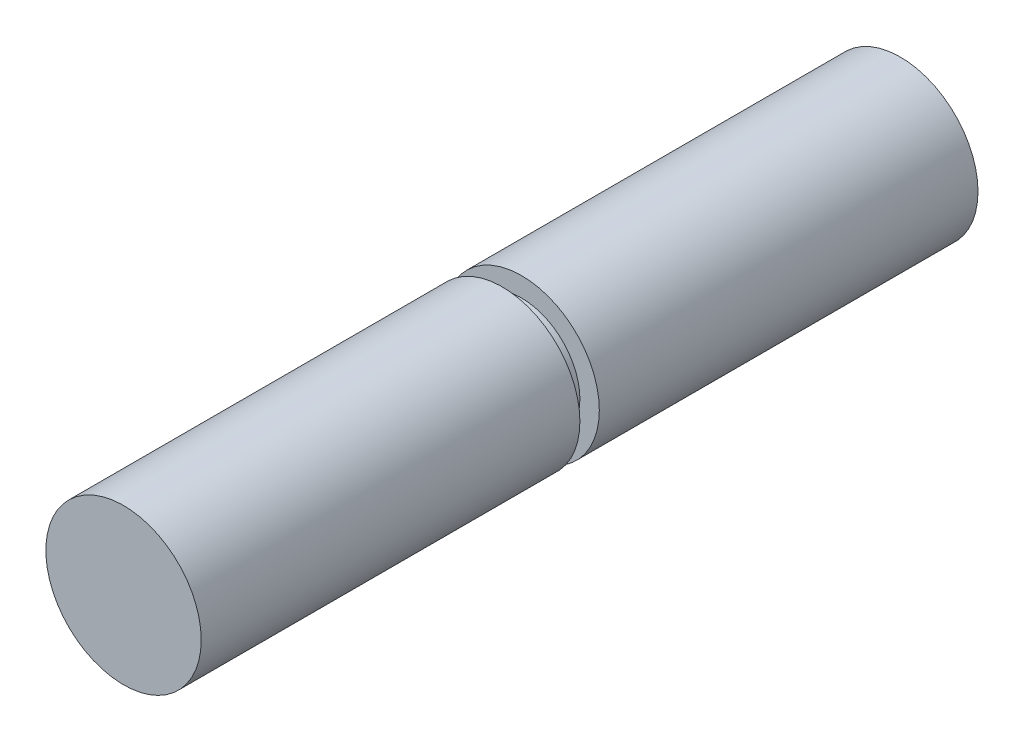
from build123d import *

# Parameters (mm, degrees)
SKETCH1_R           = 25.4
BOSS_EXTRUDE1_DEPTH = 127
SKETCH2_W           = 6.35
SKETCH2_H           = 6.35


with BuildPart() as part:
    # Sketch1 → Boss-Extrude1 (new body, symmetric)
    with BuildSketch(Plane.XY):
        Circle(SKETCH1_R)
    extrude(amount=BOSS_EXTRUDE1_DEPTH, both=True)

    # Sketch2 → Cut-Revolve1 (revolve, cut)
    with BuildSketch(Plane(origin=(0, 0, 0), x_dir=(0, 0, -1), z_dir=(1, 0, 0)), mode=Mode.PRIVATE) as cut_revolve1_sk:
        with Locations((0, 22.225)):
            Rectangle(SKETCH2_W, SKETCH2_H)
    revolve(cut_revolve1_sk.sketch.rotate(Axis((0, 0, 127), (0, 0, -1)), 90), axis=Axis((0, 0, 127), (0, 0, -1)), mode=Mode.SUBTRACT)  # turned: the seam where the file's is


solid = part.part
